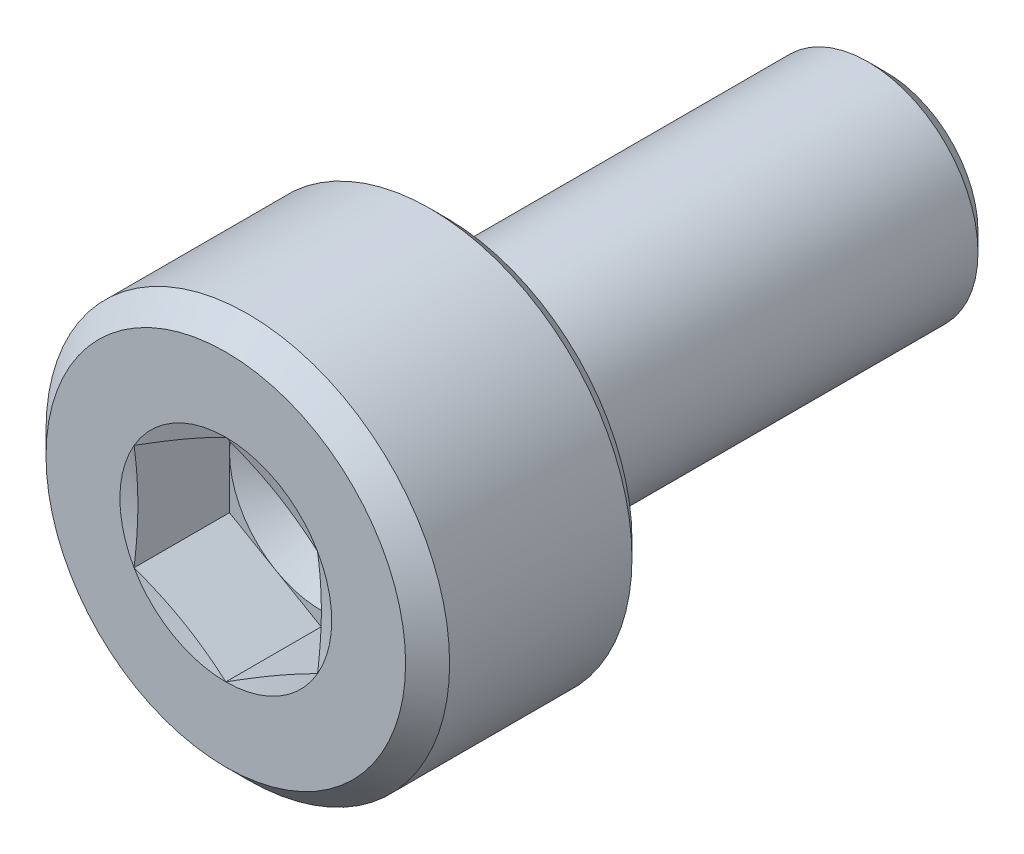
from build123d import *

# Parameters (mm, degrees)
CUT_EXTRUDE1_DEPTH = 1.3


with BuildPart() as part:
    # Sketch1 → Revolve1 (revolve)
    with BuildSketch(Plane(origin=(0, 0, 0), x_dir=(0, 0, -1), z_dir=(1, 0, 0))):
        with BuildLine():
            Line((0, 0), (0, 2.45))
            Line((0, 2.45), (0.3, 2.75))
            Line((0.3, 2.75), (2.785, 2.75))
            Line((2.785, 2.75), (3, 2.535))
            Line((3, 2.535), (3, 1.8))
            ThreePointArc((3, 1.8), (3.015193643, 1.74701055), (3.056157637, 1.710123155))
            Line((3.056157637, 1.710123155), (3.466157637, 1.510123155))
            ThreePointArc((3.466157637, 1.510123155), (3.48750205, 1.50256365), (3.51, 1.5))
            Line((3.51, 1.5), (8.75, 1.5))
            Line((8.75, 1.5), (9, 1.25))
            Line((9, 1.25), (9, 0))
            Line((9, 0), (0, 0))
        make_face()
    revolve(axis=Axis((0, 0, 0), (0, 0, -1)))

    # Sketch2 → Cut-Extrude1 (cut)
    with BuildSketch(Plane.XY):
        Polygon((0, 1.443375673), (-1.25, 0.721687836), (-1.25, -0.721687836), (0, -1.443375673), (1.25, -0.721687836), (1.25, 0.721687836), align=None)
    extrude(amount=-CUT_EXTRUDE1_DEPTH, mode=Mode.SUBTRACT)

    # Sketch3 → Cut-Revolve2 (revolve, cut)
    with BuildSketch(Plane(origin=(0, 0, 0), x_dir=(0, 0, -1), z_dir=(1, 0, 0))):
        Polygon((1.3, 0), (1.3, 1.25), (2.021687836, 0), align=None)
    revolve(axis=Axis((0, 0, -1.3), (0, 0, -1)), mode=Mode.SUBTRACT)

    # Sketch4 → Cut-Revolve3 (revolve, cut)
    with BuildSketch(Plane(origin=(0, 0, 0), x_dir=(0, 0, -1), z_dir=(1, 0, 0))):
        Polygon((0, 1.443375673), (0, 1.25), (0.051814855, 1.25), align=None)
    revolve(axis=Axis((0, 0, 0), (0, 0, -1)), mode=Mode.SUBTRACT)


solid = part.part
